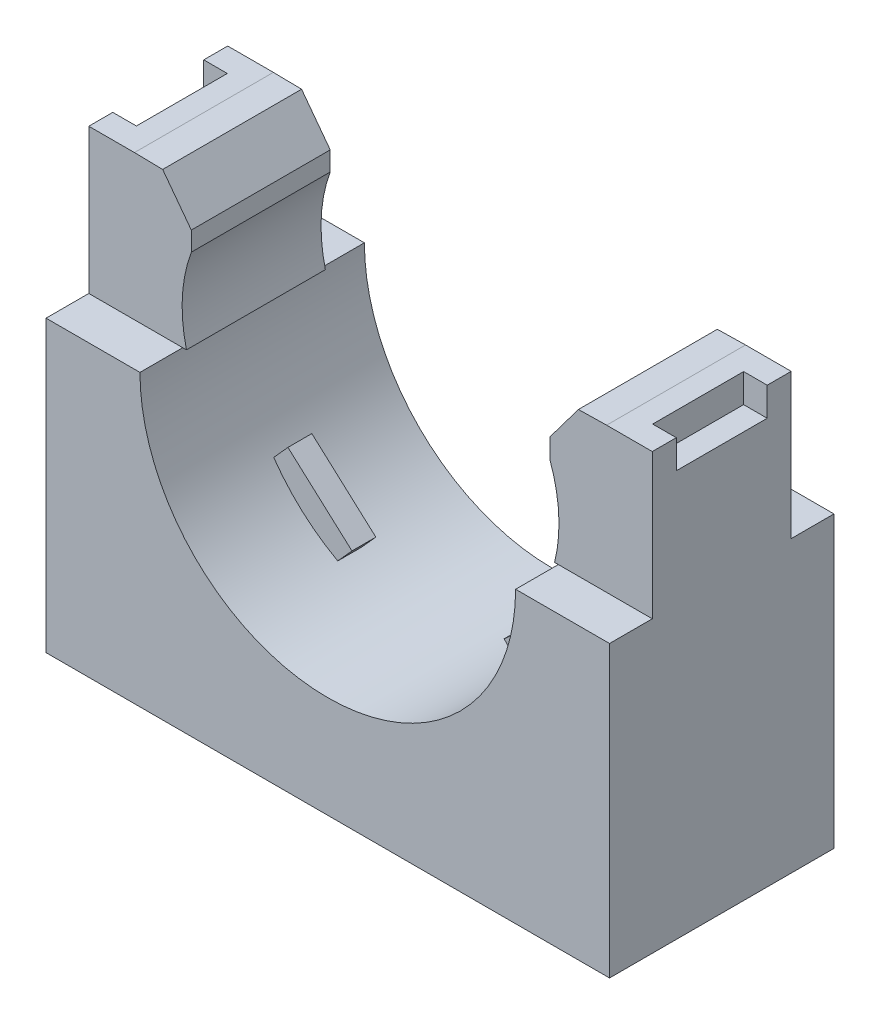
from build123d import *

# Parameters (mm, degrees)
SKETCH1_W               = 29.972
SKETCH1_H               = 23.114
EXTRUDE1_DEPTH          = 11.938
CUT_EXTRUDE1_DEPTH      = 12.938
SKETCH3_W               = 2.27457
SKETCH3_H               = 7.704666667
CUT_EXTRUDE2_DEPTH      = 15.986
CUT_EXTRUDE2_DEPTH_BACK = 15.986
SKETCH4_W               = 28.3845
SKETCH4_H               = 10.3505
CUT_EXTRUDE3_DEPTH      = 0.254
SKETCH5_W               = 1.255132872
SKETCH5_H               = 4.83743
CUT_EXTRUDE4_DEPTH      = 1.524
EXTRUDE2_DEPTH          = 0.635
CUT_EXTRUDE5_DEPTH      = 10.66343


with BuildPart() as part:
    # Sketch1 → Extrude1 (new body)
    with BuildSketch(Plane.XY):
        Rectangle(SKETCH1_W, SKETCH1_H)
    extrude(amount=EXTRUDE1_DEPTH)

    # Sketch2 → Cut-Extrude1 (cut, through all)
    with BuildSketch(Plane.XY.offset(11.938)):
        with BuildLine():
            Line((-9.990666667, 3.852333333), (-9.790853333, 3.852333333))
            ThreePointArc((-9.790853333, 3.852333333), (-10.010454448, 6.185541418), (-9.5329375, 8.479895833))
            Line((-9.5329375, 8.479895833), (-9.5329375, 11.504083333))
            Line((-9.5329375, 11.504083333), (-12.557125, 11.557))
            Line((-12.557125, 11.557), (12.557125, 11.557))
            Line((12.557125, 11.557), (9.5329375, 11.504083333))
            Line((9.5329375, 11.504083333), (9.5329375, 8.479895833))
            ThreePointArc((9.5329375, 8.479895833), (10.010454448, 6.185541418), (9.790853333, 3.852333333))
            Line((9.790853333, 3.852333333), (9.990666667, 3.852333333))
            ThreePointArc((9.990666667, 3.852333333), (0, -6.138333333), (-9.990666667, 3.852333333))
        make_face()
    extrude(amount=-CUT_EXTRUDE1_DEPTH, mode=Mode.SUBTRACT)

    # Sketch3 → Cut-Extrude2 (cut, two sides)
    with BuildSketch(Plane(origin=(0, 0, 0), x_dir=(0, 0, -1), z_dir=(1, 0, 0))) as cut_extrude2_sk:
        with Locations((-10.800715, 7.704666667)):
            Rectangle(SKETCH3_W, SKETCH3_H)
        with Locations((-1.137285, 7.704666667)):
            Rectangle(SKETCH3_W, SKETCH3_H)
    extrude(amount=CUT_EXTRUDE2_DEPTH, mode=Mode.SUBTRACT)
    extrude(cut_extrude2_sk.sketch, amount=-CUT_EXTRUDE2_DEPTH_BACK, mode=Mode.SUBTRACT)

    # Sketch4 → Cut-Extrude3 (cut)
    with BuildSketch(Plane.XZ.offset(11.557)):
        with Locations((0, 5.969)):
            Rectangle(SKETCH4_W, SKETCH4_H)
    extrude(amount=-CUT_EXTRUDE3_DEPTH, mode=Mode.SUBTRACT)

    # Sketch5 → Cut-Extrude4 (cut)
    with BuildSketch(Plane(origin=(0, 11.557, 0), x_dir=(1, 0, 0), z_dir=(0, 1, 0))):
        with Locations((-14.358433564, -5.969)):
            Rectangle(SKETCH5_W, SKETCH5_H)
        with Locations((14.358433564, -5.969)):
            Rectangle(SKETCH5_W, SKETCH5_H)
    extrude(amount=-CUT_EXTRUDE4_DEPTH, mode=Mode.SUBTRACT)

    # Sketch6 → Cut-Revolve1 (revolve, cut)
    with BuildSketch(Plane(origin=(0, 0, 5.969), x_dir=(-1, 0, 0), z_dir=(0, 0, -1)), mode=Mode.PRIVATE) as cut_revolve1_sk:
        Polygon((2.54, -11.303), (0, -11.303), (0, -6.223), (4.445, -6.223), (4.445, -8.763), (2.54, -8.763), align=None)
    revolve(cut_revolve1_sk.sketch.rotate(Axis((0, 0, 5.969), (0, -1, 0)), 270), axis=Axis((0, 0, 5.969), (0, -1, 0)), mode=Mode.SUBTRACT)  # turned: the seam where the file's is

    # Sketch7 → Extrude2 (add, symmetric)
    with BuildSketch(Plane(origin=(0, 0, 5.969), x_dir=(-1, 0, 0), z_dir=(0, 0, -1))):
        with BuildLine():
            Line((4.047558738, -4.067217721), (7.45308183, -1.000870956))
            Line((7.45308183, -1.000870956), (8.209636208, -1.841109717))
            ThreePointArc((8.209636208, -1.841109717), (6.685060845, -3.572178903), (4.804113117, -4.907456482))
            Line((4.804113117, -4.907456482), (4.047558738, -4.067217721))
        make_face()
        with BuildLine():
            Line((-4.047558738, -4.067217721), (-4.804113117, -4.907456482))
            ThreePointArc((-4.804113117, -4.907456482), (-6.685060845, -3.572178903), (-8.209636208, -1.841109717))
            Line((-8.209636208, -1.841109717), (-7.45308183, -1.000870956))
            Line((-7.45308183, -1.000870956), (-4.047558738, -4.067217721))
        make_face()
    extrude(amount=EXTRUDE2_DEPTH, both=True)

    # Sketch8 → Cut-Extrude5 (cut, through all)
    with BuildSketch(Plane.XY.offset(9.66343)):
        Polygon((-9.5329375, 11.53075), (-11.0569375, 11.53075), (-9.5329375, 9.49875), align=None)
        Polygon((9.5329375, 11.53075), (11.0569375, 11.53075), (9.5329375, 9.49875), align=None)
    extrude(amount=-CUT_EXTRUDE5_DEPTH, mode=Mode.SUBTRACT)


solid = part.part
